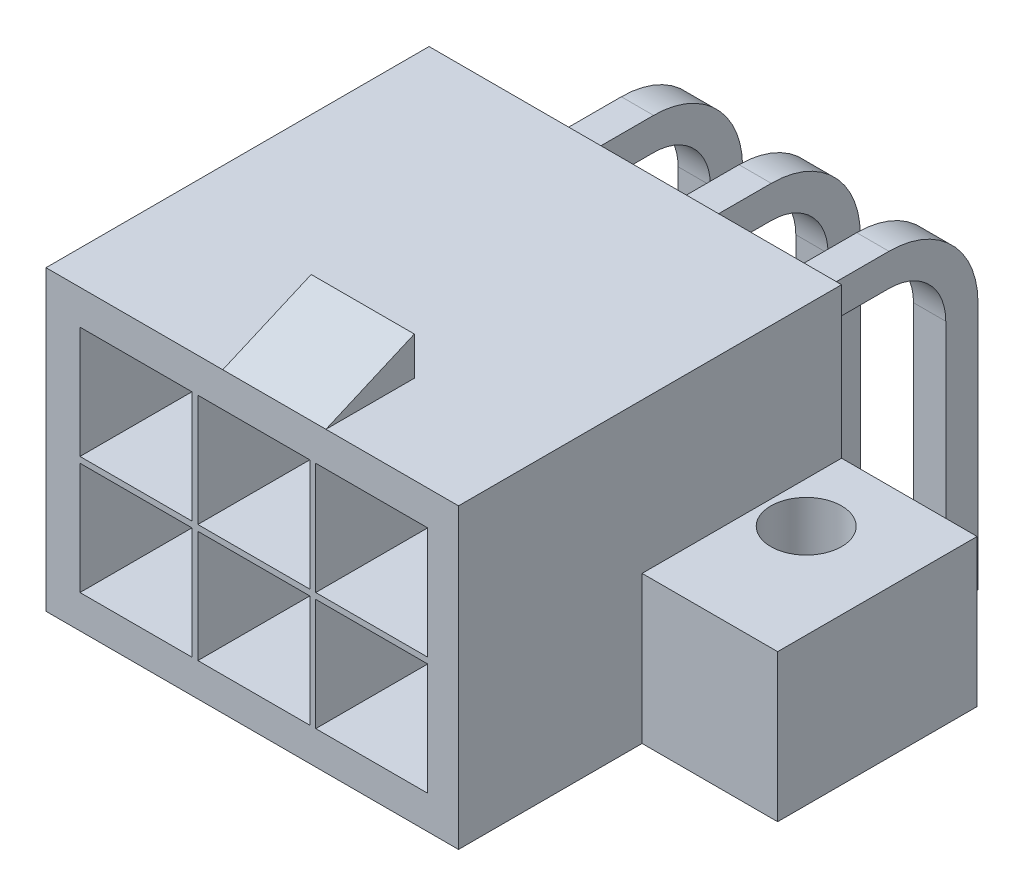
from build123d import *

# Parameters (mm, degrees)
SKETCH1_W           = 14
SKETCH1_H           = 13
BOSS_EXTRUDE1_DEPTH = 10.1
SKETCH2_W           = 3.5
SKETCH2_H           = 3
BOSS_EXTRUDE2_DEPTH = 1.3
CUT_EXTRUDE1_REACH  = 21.728
SKETCH4_W           = 6.77
SKETCH4_H           = 5
BOSS_EXTRUDE3_DEPTH = 4.6
SKETCH5_W           = 6.77
SKETCH5_H           = 5
BOSS_EXTRUDE4_DEPTH = 4.6
SKETCH6_W           = 3.8
SKETCH6_H           = 3.8
CUT_EXTRUDE2_DEPTH  = 9.2
SKETCH7_W           = 1.094306831
SKETCH7_H           = 1.09430683
SKETCH7_W_2         = 1.09430683
BOSS_EXTRUDE5_DEPTH = 10
SKETCH7_4_W         = 1.094306831
SKETCH7_4_H         = 1.09430683
SKETCH7_4_W_2       = 1.09430683
SKETCH10_W          = 1.09430683
SKETCH10_H          = 1.09
SKETCH10_W_2        = 1.077227458
SKETCH10_H_2        = 1.094306831
SKETCH10_W_3        = 1.09
SKETCH10_2_W        = 1.09430683
SKETCH10_2_H        = 1.09
SKETCH10_2_W_2      = 1.077227458
SKETCH10_2_H_2      = 1.094306831
SKETCH10_2_W_3      = 1.09
BOSS_EXTRUDE6_DEPTH = 10
SKETCH12_R          = 1.2
CUT_EXTRUDE3_DEPTH  = 30.627830836


with BuildPart() as part:
    # Sketch1 → Boss-Extrude1 (new body)
    with BuildSketch(Plane(origin=(0, 0, 0), x_dir=(1, 0, 0), z_dir=(0, 1, 0))):
        with Locations((7, 6.5)):
            Rectangle(SKETCH1_W, SKETCH1_H)
    extrude(amount=BOSS_EXTRUDE1_DEPTH)

    # Sketch2 → Boss-Extrude2 (add)
    with BuildSketch(Plane(origin=(0, 10.1, 0), x_dir=(1, 0, 0), z_dir=(0, 1, 0))):
        with Locations((7.75, 1.5)):
            Rectangle(SKETCH2_W, SKETCH2_H)
    extrude(amount=BOSS_EXTRUDE2_DEPTH)

    # Sketch3 → Cut-Extrude1 (cut, up to next)
    with BuildSketch(Plane(origin=(9.5, 0, 0), x_dir=(0, 0, -1), z_dir=(1, 0, 0)), mode=Mode.PRIVATE) as cut_extrude1_sk1:
        Polygon((0, 10.1), (3, 11.4), (0, 11.4), align=None)
    cut_extrude1_tool1 = extrude(cut_extrude1_sk1.sketch, amount=-CUT_EXTRUDE1_REACH, mode=Mode.PRIVATE) & part.part
    add(cut_extrude1_tool1.solids().sort_by_distance((9.5, 10.966667, -1))[0], mode=Mode.SUBTRACT)

    # Sketch4 → Boss-Extrude3 (add)
    with BuildSketch(Plane(origin=(14, 0, 0), x_dir=(0, 0, -1), z_dir=(1, 0, 0))):
        with Locations((9.615, 2.5)):
            Rectangle(SKETCH4_W, SKETCH4_H)
    extrude(amount=BOSS_EXTRUDE3_DEPTH)

    # Sketch5 → Boss-Extrude4 (add)
    with BuildSketch(Plane.ZY):
        with Locations((-9.615, 2.5)):
            Rectangle(SKETCH5_W, SKETCH5_H)
    extrude(amount=BOSS_EXTRUDE4_DEPTH)

    # Sketch6 → Cut-Extrude2 (cut)
    with BuildSketch(Plane.XY):
        with Locations((3.054030332, 7.029063078)):
            Rectangle(SKETCH6_W, SKETCH6_H)
        with Locations((11.054030332, 3.029063078)):
            Rectangle(SKETCH6_W, SKETCH6_H)
        with Locations((11.054030332, 7.029063078)):
            Rectangle(SKETCH6_W, SKETCH6_H)
        with Locations((3.054030332, 3.029063078)):
            Rectangle(SKETCH6_W, SKETCH6_H)
        with Locations((7.054030332, 7.029063078)):
            Rectangle(SKETCH6_W, SKETCH6_H)
        with Locations((7.054030332, 3.029063078)):
            Rectangle(SKETCH6_W, SKETCH6_H)
    extrude(amount=-CUT_EXTRUDE2_DEPTH, mode=Mode.SUBTRACT)

    # Sketch7 → Boss-Extrude5 (add)
    with BuildSketch(Plane(origin=(0, 0, -13), x_dir=(-1, 0, 0), z_dir=(0, 0, -1))):
        with Locations((-11.035767077, 7.313802256)):
            Rectangle(SKETCH7_W, SKETCH7_H)
        with Locations((-7.041460246, 7.313802256)):
            Rectangle(SKETCH7_W_2, SKETCH7_H)
        with Locations((-3.047153416, 7.313802256)):
            Rectangle(SKETCH7_W, SKETCH7_H)
    extrude(amount=-BOSS_EXTRUDE5_DEPTH)

    # Sweep2: sweep along a path in Sketch8
    with BuildLine(Plane(origin=(4, 0, 0), x_dir=(0, 0, -1), z_dir=(1, 0, 0))) as sweep2_path:
        Line((13, 7.313802256), (17.025339082, 7.313802256))
        ThreePointArc((17.025339082, 7.313802256), (18.775188598, 6.588990854), (19.5, 4.839141338))
        Line((19.5, 4.839141338), (19.5, 0))
        Line((19.5, 0), (19.5, -3.6))
    # Sketch7_4 → Sweep2 (sweep)
    with BuildSketch(Plane(origin=(0, 0, -13), x_dir=(-1, 0, 0), z_dir=(0, 0, -1))):
        with Locations((-11.035767077, 7.313802256)):
            Rectangle(SKETCH7_4_W, SKETCH7_4_H)
        with Locations((-7.041460246, 7.313802256)):
            Rectangle(SKETCH7_4_W_2, SKETCH7_4_H)
        with Locations((-3.047153416, 7.313802256)):
            Rectangle(SKETCH7_4_W, SKETCH7_4_H)
    sweep(path=sweep2_path.line)

    # Sweep3: sweep along a path in Sketch11
    with BuildLine(Plane(origin=(4, 0, 0), x_dir=(0, 0, -1), z_dir=(1, 0, 0))) as sweep3_path:
        Line((14, -3.6), (14, 0))
        Line((14, 0), (14, 1.79191881))
        ThreePointArc((14, 1.79191881), (13.707106781, 2.499025591), (13, 2.79191881))
    # Sketch10 → Sweep3 (sweep)
    with BuildSketch(Plane(origin=(0, 0, -13), x_dir=(-1, 0, 0), z_dir=(0, 0, -1))):
        with Locations((-3.0642338, 2.79191881)):
            Rectangle(SKETCH10_W, SKETCH10_H)
        with Locations((-7.049999932, 2.789495426)):
            Rectangle(SKETCH10_W_2, SKETCH10_H_2)
        with Locations((-11.033613661, 2.789495426)):
            Rectangle(SKETCH10_W_3, SKETCH10_H_2)
    sweep(path=sweep3_path.line)

    # Sketch10_2 → Boss-Extrude6 (add)
    with BuildSketch(Plane(origin=(0, 0, -13), x_dir=(-1, 0, 0), z_dir=(0, 0, -1))):
        with Locations((-3.0642338, 2.79191881)):
            Rectangle(SKETCH10_2_W, SKETCH10_2_H)
        with Locations((-7.049999932, 2.789495426)):
            Rectangle(SKETCH10_2_W_2, SKETCH10_2_H_2)
        with Locations((-11.033613661, 2.789495426)):
            Rectangle(SKETCH10_2_W_3, SKETCH10_2_H_2)
    extrude(amount=-BOSS_EXTRUDE6_DEPTH)

    # Sketch12 → Cut-Extrude3 (cut, through all)
    with BuildSketch(Plane.XZ):
        with Locations((-1.4, -10.4)):
            Circle(SKETCH12_R)
        with Locations((15.4, -10.4)):
            Circle(SKETCH12_R)
    extrude(amount=-CUT_EXTRUDE3_DEPTH, mode=Mode.SUBTRACT)


solid = part.part
